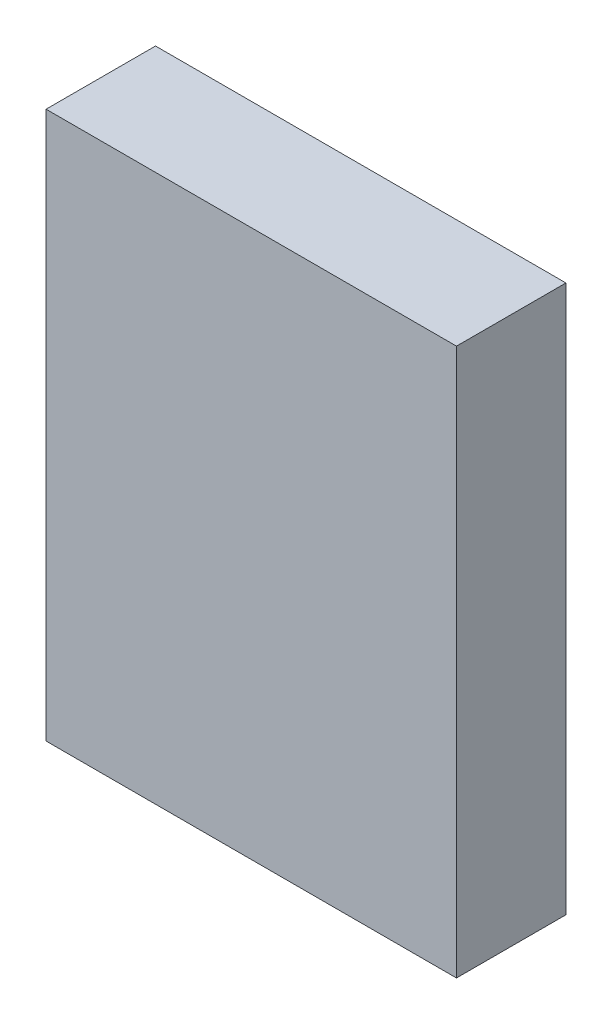
from build123d import *

# Parameters (mm, degrees)
SKETCH1_W           = 30
SKETCH1_H           = 40
BOSS_EXTRUDE1_DEPTH = 8


with BuildPart() as part:
    # Sketch1 → Boss-Extrude1 (new body)
    with BuildSketch(Plane.XY):
        Rectangle(SKETCH1_W, SKETCH1_H)
    extrude(amount=BOSS_EXTRUDE1_DEPTH)


solid = part.part
